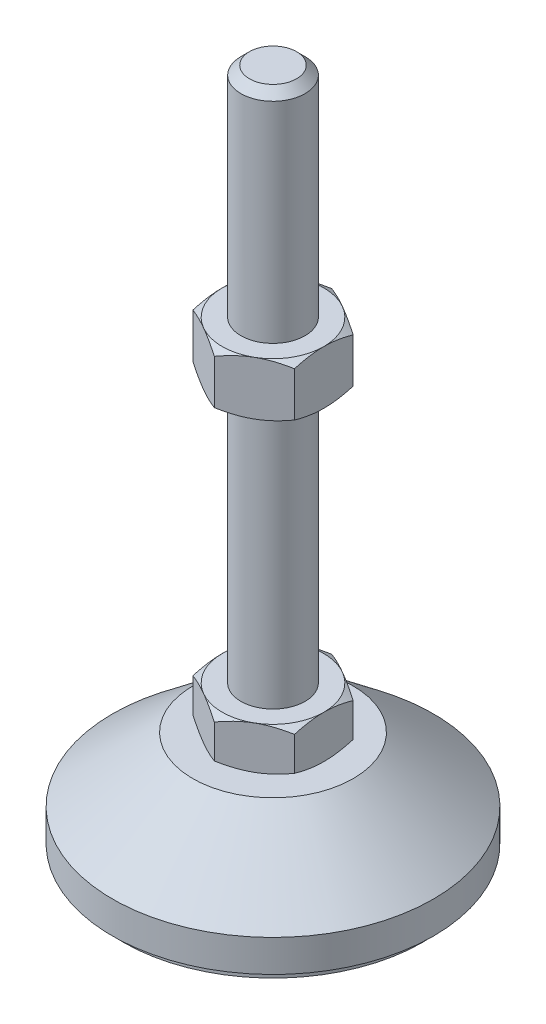
from build123d import *

# Parameters (mm, degrees)
EXTRUDE_1_DEPTH = 8
EXTRUDE_2_DEPTH = 10


with BuildPart() as part:
    # Эскиз1 → Повернуть1 (revolve)
    with BuildSketch(Plane.XY, mode=Mode.PRIVATE) as revolve_1_sk:
        Polygon((0, 0), (-28, 0), (-28, 2), (-30, 2), (-30, 8), (-15, 20), (-6, 20), (-6, 28), (-6, 126.4), (-4.4, 128), (0, 128), align=None)
    revolve(revolve_1_sk.sketch.rotate(Axis((0, 0, 0), (0, 1, 0)), 180), axis=Axis((0, 0, 0), (0, 1, 0)))  # turned: the seam where the file's is

    # Эскиз2 → Бобышка-Вытянуть1 (add)
    with BuildSketch(Plane(origin=(0, 20, 0), x_dir=(1, 0, 0), z_dir=(0, 1, 0))):
        Polygon((0, 10.969655115), (-9.5, 5.484827557), (-9.5, -5.484827557), (0, -10.969655115), (9.5, -5.484827557), (9.5, 5.484827557), align=None)
    extrude(amount=EXTRUDE_1_DEPTH)

    # Эскиз3 → Бобышка-Вытянуть2 (add)
    with BuildSketch(Plane(origin=(0, 77.2, 0), x_dir=(1, 0, 0), z_dir=(0, 1, 0))):
        Polygon((9.5, 5.484827557), (0, 10.969655115), (-9.5, 5.484827557), (-9.5, -5.484827557), (0, -10.969655115), (9.5, -5.484827557), align=None)
    extrude(amount=EXTRUDE_2_DEPTH)

    # Эскиз4 → Вырез-Повернуть2 (revolve, cut)
    with BuildSketch(Plane.XY, mode=Mode.PRIVATE) as cut_revolve_2_sk:
        Polygon((-18.160254038, 87.2), (-9.5, 87.2), (-18.160254038, 82.2), align=None)
        Polygon((-18.160254038, 77.2), (-18.160254038, 82.2), (-9.5, 77.2), align=None)
        Polygon((-16.42820323, 28), (-16.42820323, 24), (-9.5, 28), align=None)
        Polygon((-16.42820323, 24), (-16.42820323, 20), (-9.5, 20), align=None)
    revolve(cut_revolve_2_sk.sketch.rotate(Axis((0, 128, 0), (0, -1, 0)), 180), axis=Axis((0, 128, 0), (0, -1, 0)), mode=Mode.SUBTRACT)  # turned: the seam where the file's is


solid = part.part
